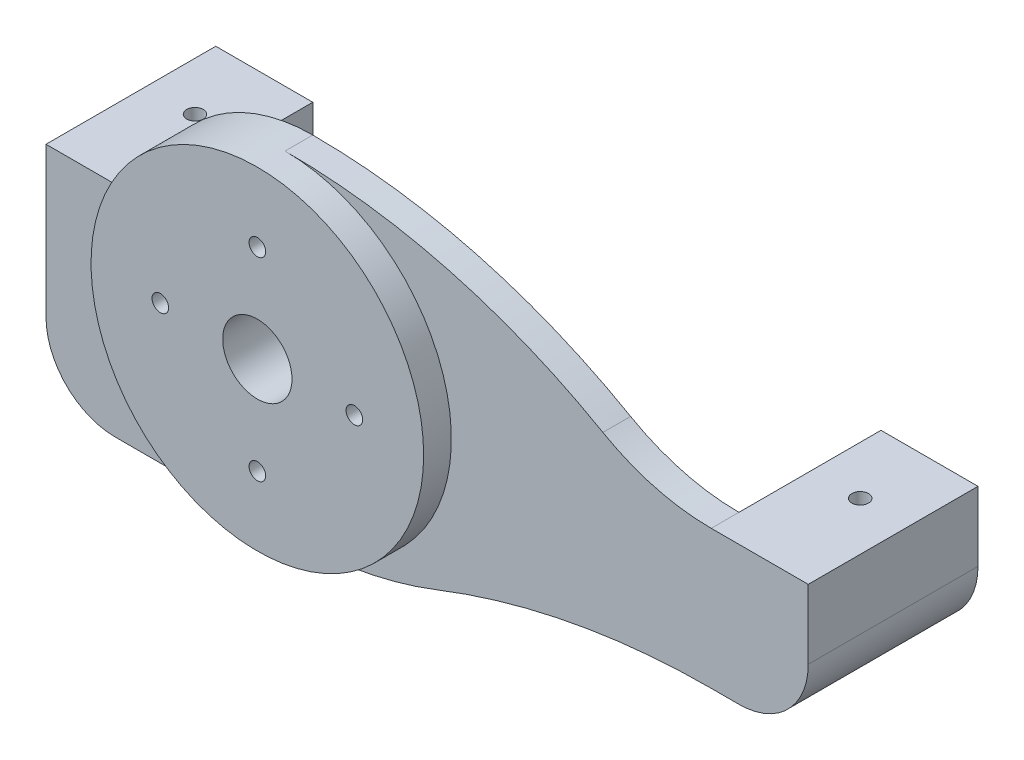
from build123d import *

# Parameters (mm, degrees)
SALIENTE_EXTRUIR1_DEPTH = 2
CROQUIS2_W              = 12.25
CROQUIS2_H              = 10
SALIENTE_EXTRUIR2_DEPTH = 7
REDONDEO1_R             = 5
CORTAR_EXTRUIR1_DEPTH   = 2
CROQUIS4_R              = 0.6
CORTAR_EXTRUIR2_DEPTH   = 7
CROQUIS5_W              = 12.25
CROQUIS5_H              = 15.8
SALIENTE_EXTRUIR3_DEPTH = 7
REDONDEO2_R             = 5
CROQUIS6_R              = 0.6
CORTAR_EXTRUIR3_DEPTH   = 9
CROQUIS7_W              = 3
CROQUIS7_H              = 6
CORTAR_EXTRUIR4_DEPTH   = 2
CROQUIS8_R              = 12
SALIENTE_EXTRUIR4_DEPTH = 2
CROQUIS9_R              = 2.5
CORTAR_EXTRUIR5_DEPTH   = 6
CROQUIS10_R             = 0.6
CORTAR_EXTRUIR6_DEPTH   = 6
CROQUIS11_R             = 3
CORTAR_EXTRUIR7_DEPTH   = 1.5
CROQUIS12_R             = 1.4
CORTAR_EXTRUIR8_DEPTH   = 10.5


with BuildPart() as part:
    # Croquis1 → Saliente-Extruir1 (new body)
    with BuildSketch(Plane.XY.offset(66.05)):
        with BuildLine():
            Line((17.240678969, 0.142768675), (17.240678969, -9.857231325))
            ThreePointArc((17.240678969, -9.857231325), (7.189890991, -10.796826624), (-2.512589694, -13.583051105))
            ThreePointArc((-2.512589694, -13.583051105), (-7.914003263, -15.134154499), (-13.509321031, -15.657231325))
            Line((-13.509321031, -15.657231325), (-25.509321031, -15.657231325))
            Line((-25.509321031, -15.657231325), (-25.509321031, -3.657231325))
            ThreePointArc((-25.509321031, -3.657231325), (-21.994602405, 4.82805005), (-13.509321031, 8.342768675))
            ThreePointArc((-13.509321031, 8.342768675), (-1.641917085, 6.787620461), (9.424079639, 2.227195163))
            ThreePointArc((9.424079639, 2.227195163), (13.195803851, 0.672823972), (17.240678969, 0.142768675))
        make_face()
    extrude(amount=SALIENTE_EXTRUIR1_DEPTH)

    # Croquis2 → Saliente-Extruir2 (add)
    with BuildSketch(Plane(origin=(17.240678969, 0, 0), x_dir=(0, 0, -1), z_dir=(1, 0, 0))):
        with Locations((-61.925, -4.857231325)):
            Rectangle(CROQUIS2_W, CROQUIS2_H)
    extrude(amount=SALIENTE_EXTRUIR2_DEPTH)

    # Redondeo1
    redondeo1_edges = [part.edges().sort_by_distance(p)[0] for p in [
        (24.240678969, -9.857231325, 61.925),
    ]]
    fillet(redondeo1_edges, radius=REDONDEO1_R)

    # Croquis3 → Cortar-Extruir1 (cut)
    with BuildSketch(Plane(origin=(0, 0, 55.8), x_dir=(-1, 0, 0), z_dir=(0, 0, -1))):
        with BuildLine():
            Line((-19.240678969, -1.857231325), (-22.240678969, -1.857231325))
            Line((-22.240678969, -1.857231325), (-22.240678969, -4.857231325))
            ThreePointArc((-22.240678969, -4.857231325), (-21.361999312, -6.978551668), (-19.240678969, -7.857231325))
            Line((-19.240678969, -7.857231325), (-19.240678969, -1.857231325))
        make_face()
    extrude(amount=-CORTAR_EXTRUIR1_DEPTH, mode=Mode.SUBTRACT)

    # Croquis4 → Cortar-Extruir2 (cut)
    with BuildSketch(Plane(origin=(0, 0.142768675, 0), x_dir=(1, 0, 0), z_dir=(0, 1, 0))):
        with Locations((20.740678969, -60.8)):
            Circle(CROQUIS4_R)
    extrude(amount=-CORTAR_EXTRUIR2_DEPTH, mode=Mode.SUBTRACT)

    # Croquis5 → Saliente-Extruir3 (add)
    with BuildSketch(Plane.ZY.offset(23.759321031)):
        with Locations((61.925, -7.757231325)):
            Rectangle(CROQUIS5_W, CROQUIS5_H)
    extrude(amount=SALIENTE_EXTRUIR3_DEPTH)

    # Redondeo2
    redondeo2_edges = [part.edges().sort_by_distance(p)[0] for p in [
        (-30.759321031, -15.657231325, 61.925),
    ]]
    fillet(redondeo2_edges, radius=REDONDEO2_R)

    # Croquis6 → Cortar-Extruir3 (cut)
    with BuildSketch(Plane(origin=(0, 0.142768675, 0), x_dir=(1, 0, 0), z_dir=(0, 1, 0))):
        with Locations((-27.259321031, -60.8)):
            Circle(CROQUIS6_R)
    extrude(amount=-CORTAR_EXTRUIR3_DEPTH, mode=Mode.SUBTRACT)

    # Croquis7 → Cortar-Extruir4 (cut)
    with BuildSketch(Plane(origin=(0, 0, 55.8), x_dir=(-1, 0, 0), z_dir=(0, 0, -1))):
        with Locations((27.259321031, -4.857231325)):
            Rectangle(CROQUIS7_W, CROQUIS7_H)
    extrude(amount=-CORTAR_EXTRUIR4_DEPTH, mode=Mode.SUBTRACT)

    # Croquis8 → Saliente-Extruir4 (add)
    with BuildSketch(Plane.XY.offset(68.05)):
        with Locations((-13.509321031, -3.657231325)):
            Circle(CROQUIS8_R)
    extrude(amount=SALIENTE_EXTRUIR4_DEPTH)

    # Croquis9 → Cortar-Extruir5 (cut)
    with BuildSketch(Plane.XY.offset(70.05)):
        with Locations((-13.509321031, -3.657231325)):
            Circle(CROQUIS9_R)
    extrude(amount=-CORTAR_EXTRUIR5_DEPTH, mode=Mode.SUBTRACT)

    # Croquis10 → Cortar-Extruir6 (cut)
    with BuildSketch(Plane.XY.offset(70.05)):
        with Locations((-13.509321031, 3.342768675)):
            Circle(CROQUIS10_R)
        with Locations((-6.509321031, -3.657231325)):
            Circle(CROQUIS10_R)
        with Locations((-13.509321031, -10.657231325)):
            Circle(CROQUIS10_R)
        with Locations((-20.509321031, -3.657231325)):
            Circle(CROQUIS10_R)
    extrude(amount=-CORTAR_EXTRUIR6_DEPTH, mode=Mode.SUBTRACT)

    # Croquis11 → Cortar-Extruir7 (cut)
    with BuildSketch(Plane(origin=(0, 0, 66.05), x_dir=(-1, 0, 0), z_dir=(0, 0, -1))):
        with Locations((13.509321031, 3.342768675)):
            Circle(CROQUIS11_R)
        with Locations((20.509321031, -3.657231325)):
            Circle(CROQUIS11_R)
        with Locations((13.509321031, -10.657231325)):
            Circle(CROQUIS11_R)
        with Locations((6.509321031, -3.657231325)):
            Circle(CROQUIS11_R)
    extrude(amount=-CORTAR_EXTRUIR7_DEPTH, mode=Mode.SUBTRACT)

    # Croquis12 → Cortar-Extruir8 (cut)
    with BuildSketch(Plane(origin=(0, 0, 55.8), x_dir=(-1, 0, 0), z_dir=(0, 0, -1))):
        with Locations((27.259321031, -10.857231325)):
            Circle(CROQUIS12_R)
    extrude(amount=-CORTAR_EXTRUIR8_DEPTH, mode=Mode.SUBTRACT)


solid = part.part
